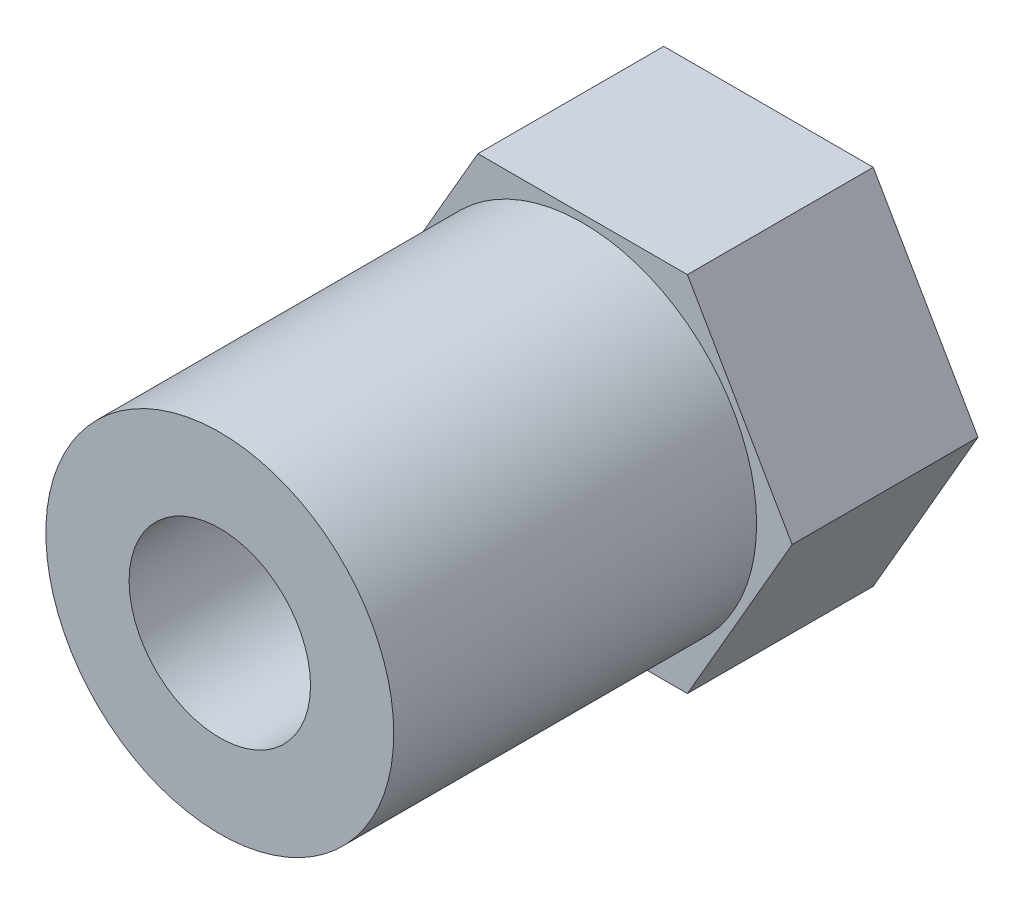
from build123d import *

# Parameters (mm, degrees)
SKETCH1_R           = 1.6383
BOSS_EXTRUDE1_DEPTH = 6.1468
SKETCH2_R           = 5.7531
SKETCH2_R_2         = 3
BOSS_EXTRUDE2_DEPTH = 12


with BuildPart() as part:
    # Sketch1 → Boss-Extrude1 (new body)
    with BuildSketch(Plane.XY):
        Polygon((6.92820323, 0), (3.464101615, 6), (-3.464101615, 6), (-6.92820323, 0), (-3.464101615, -6), (3.464101615, -6), align=None)
        Circle(SKETCH1_R, mode=Mode.SUBTRACT)
    extrude(amount=BOSS_EXTRUDE1_DEPTH)

    # Sketch2 → Boss-Extrude2 (add)
    with BuildSketch(Plane.XY.offset(6.1468)):
        Circle(SKETCH2_R)
        Circle(SKETCH2_R_2, mode=Mode.SUBTRACT)
    extrude(amount=BOSS_EXTRUDE2_DEPTH)


solid = part.part
